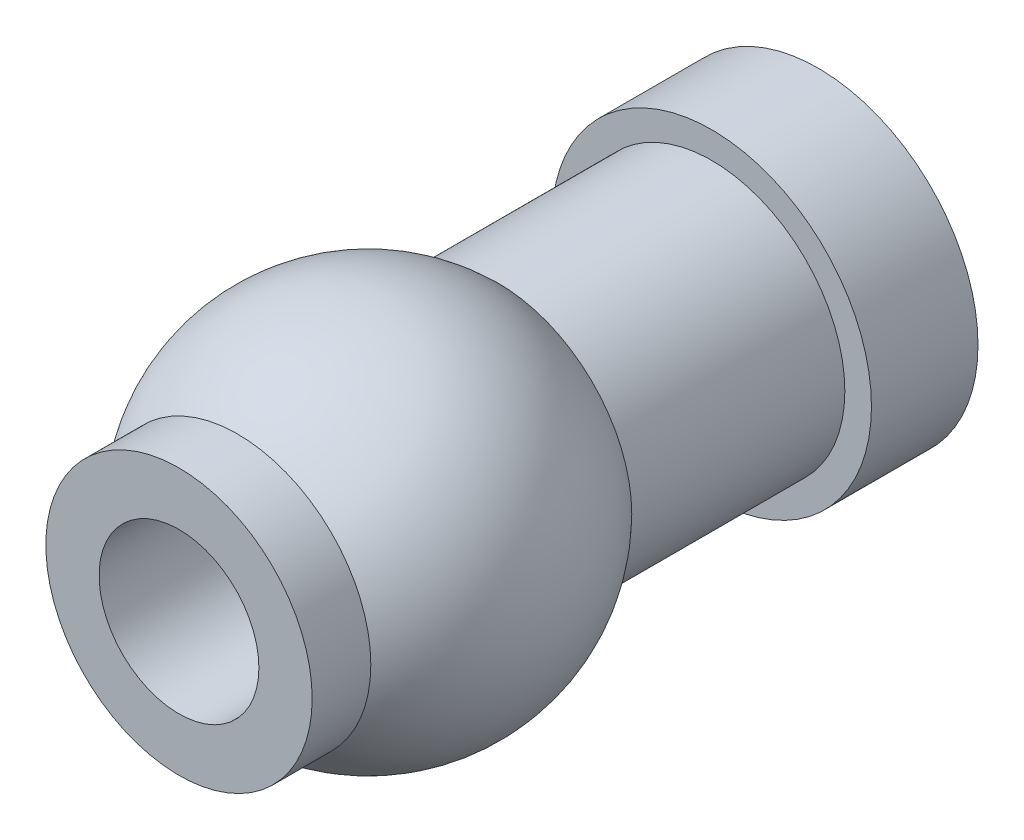
from build123d import *


with BuildPart() as part:
    # Sketch1 → Revolve1 (revolve)
    with BuildSketch(Plane(origin=(0, 0, 0), x_dir=(0, 0, -1), z_dir=(1, 0, 0))):
        with BuildLine():
            Line((0.388232597, 1.5), (6.712787917, 1.5))
            ThreePointArc((6.712787917, 1.5), (6.400595054, 2.031506006), (6, 2.5))
            ThreePointArc((6, 2.5), (3.550510257, 3.5), (1.101020514, 2.5))
            ThreePointArc((1.101020514, 2.5), (0.700425461, 2.031506006), (0.388232597, 1.5))
        make_face()
        with BuildLine():
            Line((6.712787917, 1.5), (12, 1.5))
            Line((12, 1.5), (12, 3))
            Line((12, 3), (10, 3))
            Line((10, 3), (10, 2.5))
            Line((10, 2.5), (6, 2.5))
            ThreePointArc((6, 2.5), (6.400595054, 2.031506006), (6.712787917, 1.5))
        make_face()
        with BuildLine():
            Line((0, 1.5), (0.388232597, 1.5))
            ThreePointArc((0.388232597, 1.5), (0.700425461, 2.031506006), (1.101020514, 2.5))
            Line((1.101020514, 2.5), (0, 2.5))
            Line((0, 2.5), (0, 1.5))
        make_face()
    revolve(axis=Axis((0, 0, 0), (0, 0, -1)))


solid = part.part
